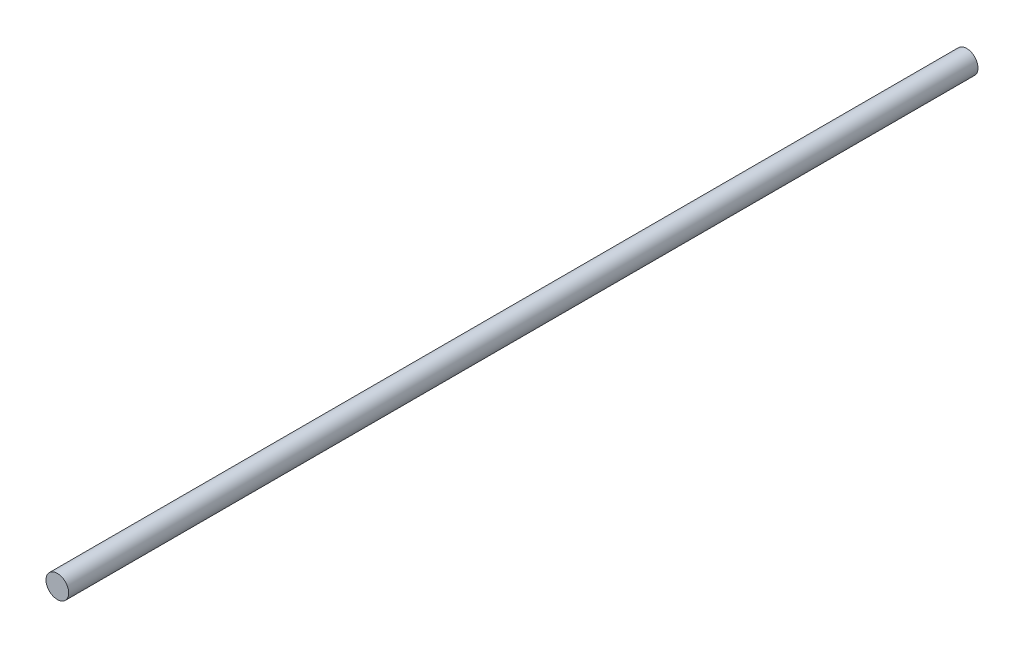
from build123d import *

# Parameters (mm, degrees)
SKETCH1_R           = 3
BOSS_EXTRUDE1_DEPTH = 240


with BuildPart() as part:
    # Sketch1 → Boss-Extrude1 (new body)
    with BuildSketch(Plane.XY):
        Circle(SKETCH1_R)
    extrude(amount=BOSS_EXTRUDE1_DEPTH)


solid = part.part
